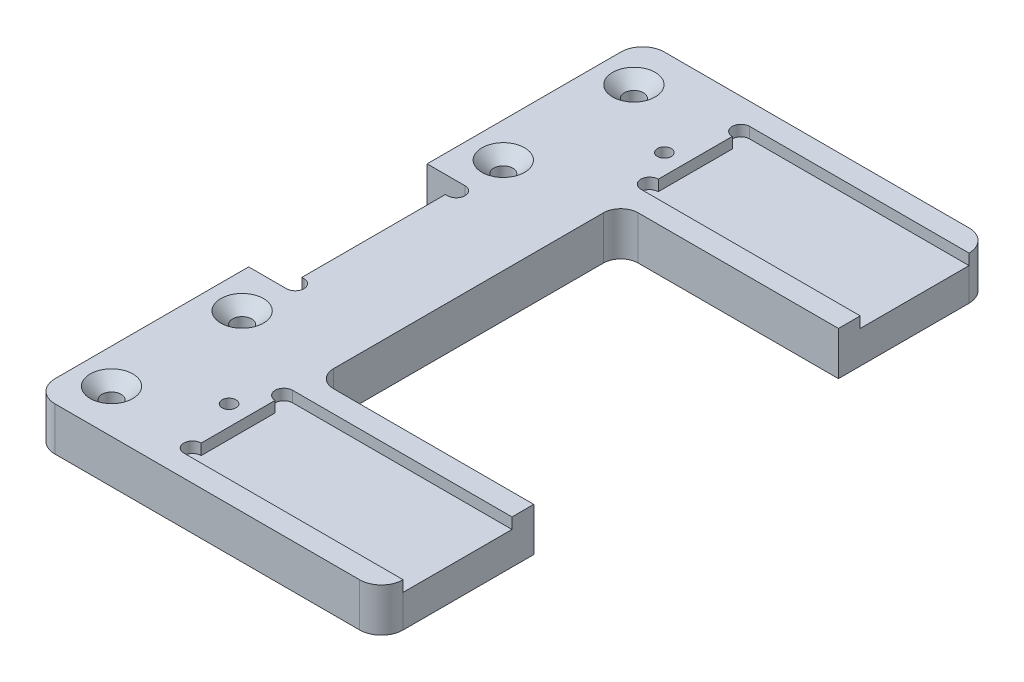
from build123d import *

# Parameters (mm, degrees)
BOSS_EXTRUDE1_DEPTH                                 = 5
FILLET1_R                                           = 2
FILLET2_R                                           = 2.5
CUT_EXTRUDE2_REACH                                  = 7
CSK_FOR_M2_COUNTERSUNK_FLAT_HEAD_SCREW1_D           = 2.2
CSK_FOR_M2_COUNTERSUNK_FLAT_HEAD_SCREW1_DEPTH       = 5
CSK_FOR_M2_COUNTERSUNK_FLAT_HEAD_SCREW1_CSINK_D     = 4.9
CSK_FOR_M2_COUNTERSUNK_FLAT_HEAD_SCREW1_CSINK_ANGLE = 90
M2_TAPPED_HOLE1_D                                   = 1.6
M2_TAPPED_HOLE1_DEPTH                               = 5
SKETCH9_W                                           = 25.2
SKETCH9_H                                           = 12.5
CUT_EXTRUDE3_DEPTH                                  = 1.25
CUT_EXTRUDE4_DEPTH                                  = 1.25


with BuildPart() as part:
    # Sketch1 → Boss-Extrude1 (new body)
    with BuildSketch(Plane(origin=(0, 0, 0), x_dir=(1, 0, 0), z_dir=(0, 1, 0))):
        Polygon((0, 35), (0, 10.25), (4.1, 10.25), (4.1, -10.25), (0, -10.25), (0, -35), (40, -35), (40, -17.5), (15, -17.5), (15, 17.5), (40, 17.5), (40, 35), align=None)
    extrude(amount=BOSS_EXTRUDE1_DEPTH)

    # Fillet1
    fillet1_edges = [part.edges().sort_by_distance(p)[0] for p in [
        (15, 2.5, -17.5),
        (15, 2.5, 17.5),
    ]]
    fillet(fillet1_edges, radius=FILLET1_R)

    # Fillet2
    fillet2_edges = [part.edges().sort_by_distance(p)[0] for p in [
        (0, 2.5, -35),
        (40, 2.5, -35),
        (40, 2.5, 35),
        (0, 2.5, 35),
    ]]
    fillet(fillet2_edges, radius=FILLET2_R)

    # Sketch3 → Cut-Extrude2 (cut, up to next)
    with BuildSketch(Plane(origin=(0, 5, 0), x_dir=(1, 0, 0), z_dir=(0, 1, 0)), mode=Mode.PRIVATE) as cut_extrude2_sk1:
        with BuildLine():
            Line((4.1, 10.25), (4.35, 10.25))
            ThreePointArc((4.35, 10.25), (5.35, 9.25), (4.35, 8.25))
            Line((4.35, 8.25), (4.1, 8.25))
            Line((4.1, 8.25), (4.1, 10.25))
        make_face()
    cut_extrude2_tool1 = extrude(cut_extrude2_sk1.sketch, amount=-CUT_EXTRUDE2_REACH, mode=Mode.PRIVATE) & part.part
    add(cut_extrude2_tool1.solids().sort_by_distance((4.641756, 5, -9.25))[0], mode=Mode.SUBTRACT)
    # Sketch3 → Cut-Extrude2 (cut, up to next)
    with BuildSketch(Plane(origin=(0, 5, 0), x_dir=(1, 0, 0), z_dir=(0, 1, 0)), mode=Mode.PRIVATE) as cut_extrude2_sk2:
        with BuildLine():
            Line((4.1, -10.25), (4.1, -8.25))
            Line((4.1, -8.25), (4.35, -8.25))
            ThreePointArc((4.35, -8.25), (5.35, -9.25), (4.35, -10.25))
            Line((4.35, -10.25), (4.1, -10.25))
        make_face()
    cut_extrude2_tool2 = extrude(cut_extrude2_sk2.sketch, amount=-CUT_EXTRUDE2_REACH, mode=Mode.PRIVATE) & part.part
    add(cut_extrude2_tool2.solids().sort_by_distance((4.641756, 5, 9.25))[0], mode=Mode.SUBTRACT)

    # CSK for M2 Countersunk Flat Head Screw1
    with Locations(Plane(origin=(0, 5, 0), x_dir=(1, 0, 0), z_dir=(0, 1, 0))):
        with Locations((4, 30), (4, 15), (4, -15), (4, -30)):
            csk_for_m2_countersunk_flat_head_screw1 = CounterSinkHole(CSK_FOR_M2_COUNTERSUNK_FLAT_HEAD_SCREW1_D / 2, CSK_FOR_M2_COUNTERSUNK_FLAT_HEAD_SCREW1_CSINK_D / 2, depth=CSK_FOR_M2_COUNTERSUNK_FLAT_HEAD_SCREW1_DEPTH, counter_sink_angle=CSK_FOR_M2_COUNTERSUNK_FLAT_HEAD_SCREW1_CSINK_ANGLE)

    # M2 Tapped Hole1
    with Locations(Plane(origin=(0, 5, 0), x_dir=(1, 0, 0), z_dir=(0, 1, 0))):
        with Locations((12.5, -25), (12.5, 25)):
            Hole(M2_TAPPED_HOLE1_D / 2, depth=M2_TAPPED_HOLE1_DEPTH)

    # Sketch9 → Cut-Extrude3 (cut)
    with BuildSketch(Plane(origin=(0, 5, 0), x_dir=(1, 0, 0), z_dir=(0, 1, 0))):
        with Locations((27.4, 26.25)):
            Rectangle(SKETCH9_W, SKETCH9_H)
        with Locations((27.4, -26.25)):
            Rectangle(SKETCH9_W, SKETCH9_H)
    extrude(amount=-CUT_EXTRUDE3_DEPTH, mode=Mode.SUBTRACT)

    # Sketch10 → Cut-Extrude4 (cut)
    with BuildSketch(Plane(origin=(0, 5, 0), x_dir=(1, 0, 0), z_dir=(0, 1, 0))):
        with BuildLine():
            Line((14.8, 22), (14.8, 20))
            ThreePointArc((14.8, 20), (13.8, 21), (14.8, 22))
        make_face()
        with BuildLine():
            Line((14.8, 30.5), (14.8, 32.5))
            ThreePointArc((14.8, 32.5), (13.8, 31.5), (14.8, 30.5))
        make_face()
    cut_extrude4 = extrude(amount=-CUT_EXTRUDE4_DEPTH, mode=Mode.SUBTRACT)

    # Mirror1: CSK for M2 Countersunk Flat Head Screw1 across plane
    add(csk_for_m2_countersunk_flat_head_screw1.mirror(Plane(origin=(0, 2.5, 0), x_dir=(0, 0, 1), z_dir=(0, -1, 0))), mode=Mode.SUBTRACT)

    # Mirror2: Cut-Extrude4 across plane
    add(cut_extrude4.mirror(Plane.XY), mode=Mode.SUBTRACT)


solid = part.part
